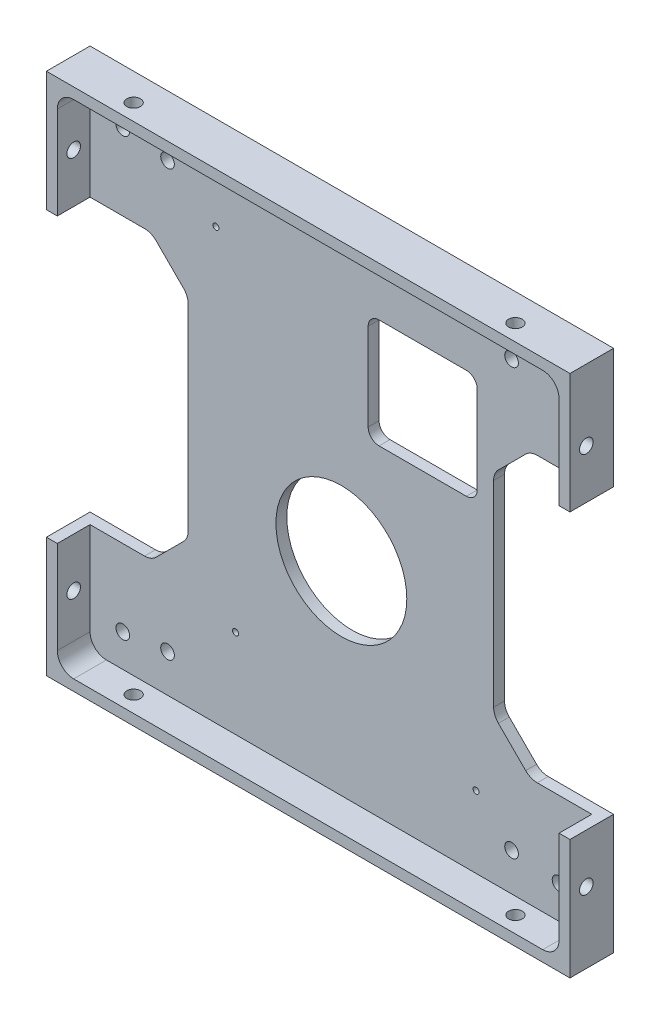
from build123d import *

# Parameters (mm, degrees)
SKETCH1_W                      = 96
SKETCH1_H                      = 96
BOSS_EXTRUDE1_DEPTH            = 8
SKETCH2_W                      = 92
SKETCH2_H                      = 92
COMPONENT_PLATFORM_DEPTH       = 6
CABLE_SLOTS_DEPTH              = 6
INNER_CORNER_FILLETS_R         = 3
M3X0_5_TAPPED_HOLE1_AT_2_COUNT = 2
M3X0_5_TAPPED_HOLE1_AT_2_PITCH = 70
M3X0_5_TAPPED_HOLE2_AT_2_COUNT = 2
M3X0_5_TAPPED_HOLE2_AT_2_PITCH = 70
M1_4X0_3_TAPPED_HOLE1_D        = 1.1
M1_4X0_3_TAPPED_HOLE1_DEPTH    = 3.7
M1_4X0_3_TAPPED_HOLE1_TIP      = 0.33047334
SKETCH29_R                     = 12
HDD_EXTRUSION_CUTOUT_DEPTH     = 10
HDD_EXTRUSION_CUTOUT_2_DEPTH   = 10
M3X0_5_TAPPED_HOLE3_D          = 2.5
M3X0_5_TAPPED_HOLE3_DEPTH      = 10
M3X0_5_TAPPED_HOLE3_TIP        = 0.751075774
M3X0_5_TAPPED_HOLE4_D          = 2.5


with BuildPart() as part:
    # Sketch1 → Boss-Extrude1 (new body)
    with BuildSketch(Plane.XY):
        Rectangle(SKETCH1_W, SKETCH1_H)
    extrude(amount=BOSS_EXTRUDE1_DEPTH)

    # Sketch2 → Component Platform (cut)
    with BuildSketch(Plane.XY.offset(8)):
        Rectangle(SKETCH2_W, SKETCH2_H)
    extrude(amount=-COMPONENT_PLATFORM_DEPTH, mode=Mode.SUBTRACT)

    # Sketch3 → Cable Slots (cut, symmetric)
    with BuildSketch(Plane.XY.offset(2)):
        with BuildLine():
            Line((-33.878679656, -25.121320344), (-28.878679656, -20.121320344))
            ThreePointArc((-28.878679656, -20.121320344), (-28.228361402, -19.148050297), (-28, -18))
            Line((-28, -18), (-28, 18))
            ThreePointArc((-28, 18), (-28.228361402, 19.148050297), (-28.878679656, 20.121320344))
            Line((-28.878679656, 20.121320344), (-33.878679656, 25.121320344))
            ThreePointArc((-33.878679656, 25.121320344), (-34.851949703, 25.771638598), (-36, 26))
            Line((-36, 26), (-48, 26))
            Line((-48, 26), (-48, -26))
            Line((-48, -26), (-36, -26))
            ThreePointArc((-36, -26), (-34.851949703, -25.771638598), (-33.878679656, -25.121320344))
        make_face()
        with BuildLine():
            Line((48, -26), (48, 26))
            Line((48, 26), (36, 26))
            ThreePointArc((36, 26), (34.851949703, 25.771638598), (33.878679656, 25.121320344))
            Line((33.878679656, 25.121320344), (28.878679656, 20.121320344))
            ThreePointArc((28.878679656, 20.121320344), (28.228361402, 19.148050297), (28, 18))
            Line((28, 18), (28, -18))
            ThreePointArc((28, -18), (28.228361402, -19.148050297), (28.878679656, -20.121320344))
            Line((28.878679656, -20.121320344), (33.878679656, -25.121320344))
            ThreePointArc((33.878679656, -25.121320344), (34.851949703, -25.771638598), (36, -26))
            Line((36, -26), (48, -26))
        make_face()
    extrude(amount=CABLE_SLOTS_DEPTH, both=True, mode=Mode.SUBTRACT)

    # Inner Corner Fillets
    inner_corner_fillets_edges = [part.edges().sort_by_distance(p)[0] for p in [
        (-46, -46, 5),
        (-46, 46, 5),
        (46, 46, 5),
        (46, -46, 5),
    ]]
    fillet(inner_corner_fillets_edges, radius=INNER_CORNER_FILLETS_R)

    # Sketch14 → M3x0.5 Tapped Hole1 (revolve, cut)
    with BuildSketch(Plane(origin=(48, -35, 5), x_dir=(0, 0, -1), z_dir=(0, 1, 0))):
        Polygon((0, 0), (0, 10.751075774), (1.25, 10), (1.25, 0), align=None)
    m3x0_5_tapped_hole1 = revolve(axis=Axis((54.35, -35, 5), (-1, 0, 0)), mode=Mode.SUBTRACT)

    # M3x0.5 Tapped Hole1 at 2: M3x0.5 Tapped Hole1 ×2
    with Locations(*[(0, i * M3X0_5_TAPPED_HOLE1_AT_2_PITCH, 0) for i in range(1, M3X0_5_TAPPED_HOLE1_AT_2_COUNT)]):
        add(m3x0_5_tapped_hole1, mode=Mode.SUBTRACT)

    # Sketch16 → M3x0.5 Tapped Hole2 (revolve, cut)
    with BuildSketch(Plane(origin=(35, 48, 5), x_dir=(0, 0, 1), z_dir=(1, 0, 0))):
        Polygon((0, 0), (0, 10.751075774), (1.25, 10), (1.25, 0), align=None)
    m3x0_5_tapped_hole2 = revolve(axis=Axis((35, 54.35, 5), (0, -1, 0)), mode=Mode.SUBTRACT)

    # M3x0.5 Tapped Hole2 at 2: M3x0.5 Tapped Hole2 ×2
    with Locations(*[(-i * M3X0_5_TAPPED_HOLE2_AT_2_PITCH, 0, 0) for i in range(1, M3X0_5_TAPPED_HOLE2_AT_2_COUNT)]):
        add(m3x0_5_tapped_hole2, mode=Mode.SUBTRACT)

    # Mirror1: M3x0.5 Tapped Hole1 across plane
    add(m3x0_5_tapped_hole1.mirror(Plane(origin=(0, 0, 0), x_dir=(0, 0, 1), z_dir=(1, 0, 0))), mode=Mode.SUBTRACT)

    # Mirror1 copy 1 sketch → Mirror1 copy 1 (revolve, cut)
    with BuildSketch(Plane(origin=(-48, 35, 5), x_dir=(0, 0, -1), z_dir=(0, 1, 0))):
        Polygon((0, 0), (0, -10.751075774), (1.25, -10), (1.25, 0), align=None)
    revolve(axis=Axis((-54.35, 35, 5), (-1, 0, 0)), mode=Mode.SUBTRACT)

    # Mirror2: M3x0.5 Tapped Hole2 across plane
    add(m3x0_5_tapped_hole2.mirror(Plane(origin=(0, 0, 0), x_dir=(0, 0, 1), z_dir=(0, -1, 0))), mode=Mode.SUBTRACT)

    # Mirror2 copy 1 sketch → Mirror2 copy 1 (revolve, cut)
    with BuildSketch(Plane(origin=(-35, -48, 5), x_dir=(0, 0, 1), z_dir=(1, 0, 0))):
        Polygon((0, 0), (0, -10.751075774), (1.25, -10), (1.25, 0), align=None)
    revolve(axis=Axis((-35, -54.35, 5), (0, -1, 0)), mode=Mode.SUBTRACT)

    # M1.4x0.3 Tapped Hole1
    with Locations(Plane.XY.offset(2)):
        with Locations((-19.31998517, -29.75), (24.78001483, -32.85), (-22.91998517, 32.85)):
            Hole(M1_4X0_3_TAPPED_HOLE1_D / 2, depth=M1_4X0_3_TAPPED_HOLE1_DEPTH)
            with Locations((0, 0, -(M1_4X0_3_TAPPED_HOLE1_DEPTH + M1_4X0_3_TAPPED_HOLE1_TIP / 2))):  # 118° drill point
                Cone(0, M1_4X0_3_TAPPED_HOLE1_D / 2, M1_4X0_3_TAPPED_HOLE1_TIP, mode=Mode.SUBTRACT)

    # Sketch29 → HDD Extrusion Cutout (cut)
    with BuildSketch(Plane(origin=(0, 0, 0), x_dir=(-1, 0, 0), z_dir=(0, 0, -1))):
        with Locations((-0.08192631, -8.74785827)):
            Circle(SKETCH29_R)
    extrude(amount=-HDD_EXTRUSION_CUTOUT_DEPTH, mode=Mode.SUBTRACT)

    # Sketch9 → HDD Extrusion Cutout 2 (cut)
    with BuildSketch(Plane.XY.offset(2)):
        with BuildLine():
            Line((25, 31), (25, 15))
            ThreePointArc((25, 15), (24.414213562, 13.585786438), (23, 13))
            Line((23, 13), (7, 13))
            ThreePointArc((7, 13), (5.585786438, 13.585786438), (5, 15))
            Line((5, 15), (5, 31))
            ThreePointArc((5, 31), (5.585786438, 32.414213562), (7, 33))
            Line((7, 33), (23, 33))
            ThreePointArc((23, 33), (24.414213562, 32.414213562), (25, 31))
        make_face()
    extrude(amount=-HDD_EXTRUSION_CUTOUT_2_DEPTH, mode=Mode.SUBTRACT)

    # M3x0.5 Tapped Hole3
    with Locations(Plane.XY.offset(2)):
        with Locations((-31.790998517, -39.06), (31.29001483, -39.06), (31.29001483, 38.94), (-31.790998517, 38.94)):
            Hole(M3X0_5_TAPPED_HOLE3_D / 2, depth=M3X0_5_TAPPED_HOLE3_DEPTH)
            with Locations((0, 0, -(M3X0_5_TAPPED_HOLE3_DEPTH + M3X0_5_TAPPED_HOLE3_TIP / 2))):  # 118° drill point
                Cone(0, M3X0_5_TAPPED_HOLE3_D / 2, M3X0_5_TAPPED_HOLE3_TIP, mode=Mode.SUBTRACT)

    # M3x0.5 Tapped Hole4 (through all)
    with Locations(Plane.XY.offset(2)):
        with Locations((40, -40), (-40, -40), (-40, 40), (40, 40)):
            Hole(M3X0_5_TAPPED_HOLE4_D / 2)


solid = part.part
